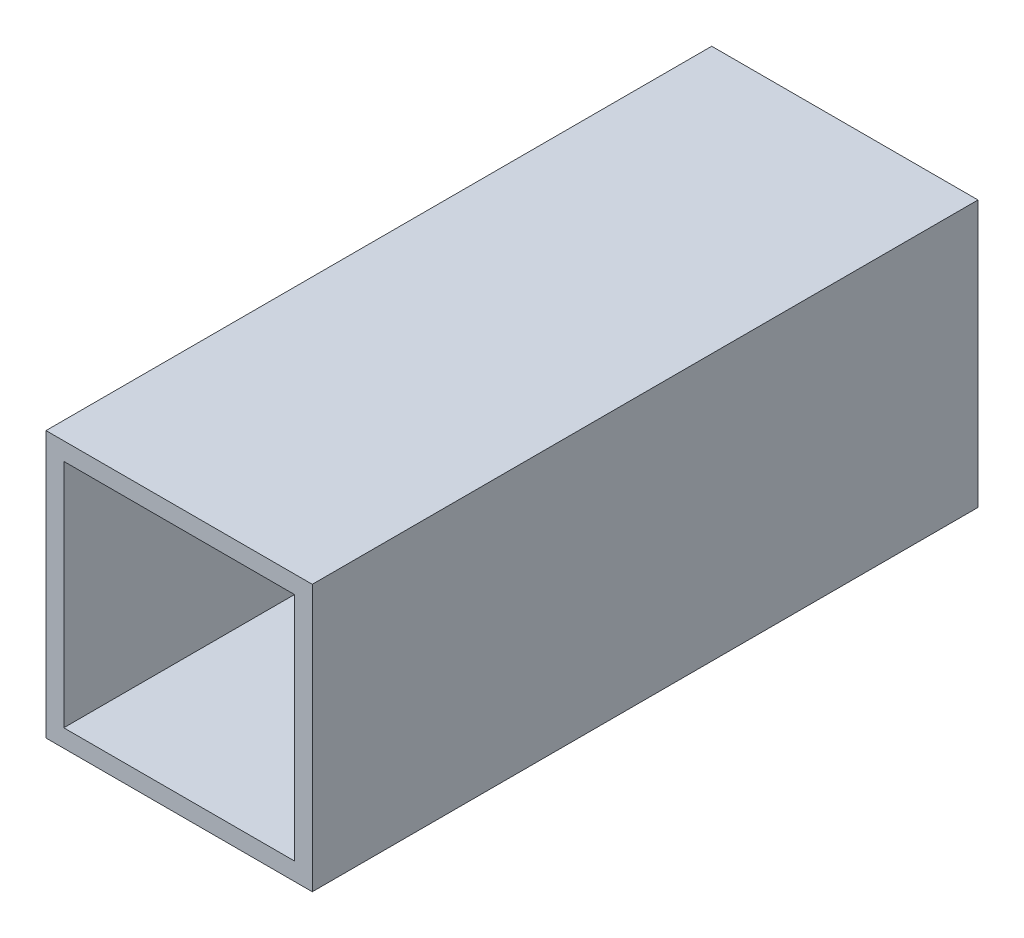
from build123d import *

# Parameters (mm, degrees)
SZKIC1_W                    = 60
SZKIC1_H                    = 60
SZKIC1_W_2                  = 52
SZKIC1_H_2                  = 52
DODANIE_WYCI_GNI_CIE1_DEPTH = 75
SZKIC28_R                   = 5
WYTNIJ_WYCI_GNI_CIE1_DEPTH  = 25


with BuildPart() as part:
    # Szkic1 → Dodanie-wyciągnięcie1 (new body, symmetric)
    with BuildSketch(Plane.XY):
        Rectangle(SZKIC1_W, SZKIC1_H)
        Rectangle(SZKIC1_W_2, SZKIC1_H_2, mode=Mode.SUBTRACT)
    extrude(amount=DODANIE_WYCI_GNI_CIE1_DEPTH, both=True)

    # Szkic28 → Wytnij-wyciągnięcie1 (cut)
    with BuildSketch(Plane.ZY.offset(30)):
        Circle(SZKIC28_R)
    extrude(amount=-WYTNIJ_WYCI_GNI_CIE1_DEPTH, mode=Mode.SUBTRACT)


solid = part.part
